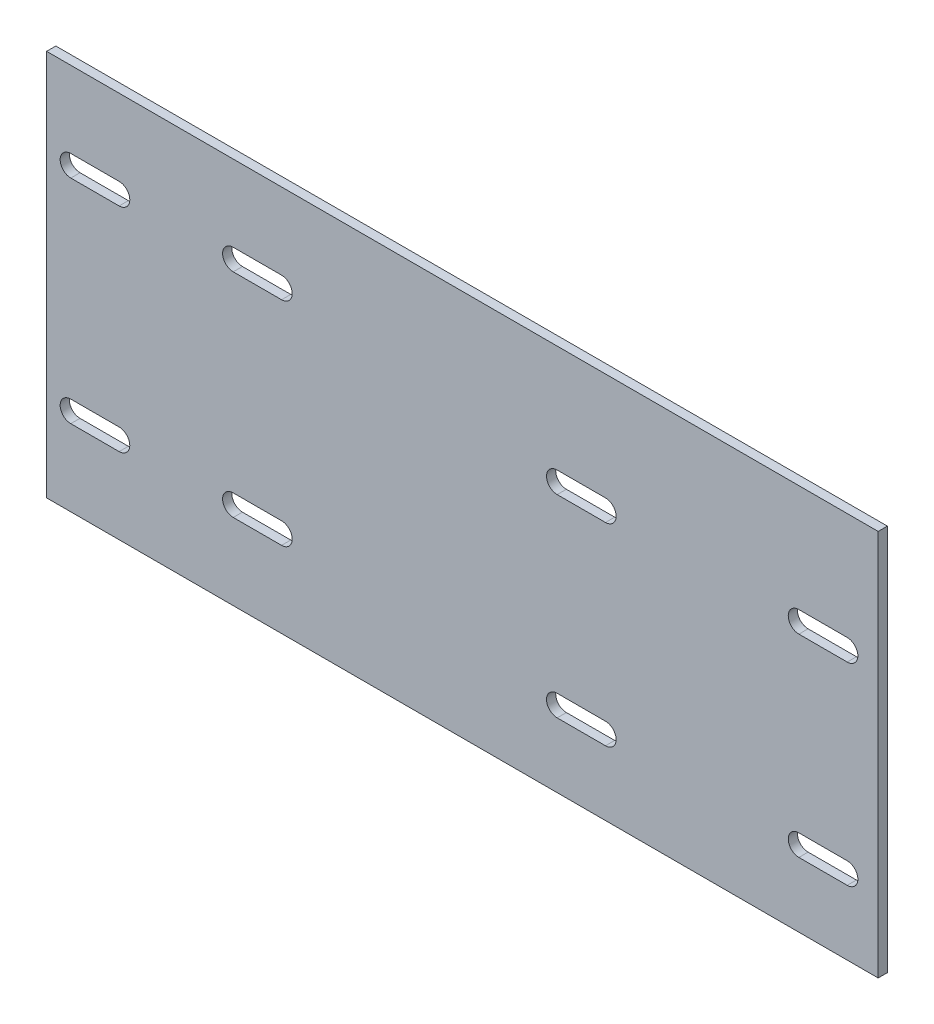
from build123d import *

# Parameters (mm, degrees)
ESBO_O1_W                = 430
ESBO_O1_H                = 200
RESSALTO_EXTRUS_O1_DEPTH = 4.7625
CORTE_EXTRUS_O1_DEPTH    = 5.7625


with BuildPart() as part:
    # Esboço1 → Ressalto-extrusão1 (new body)
    with BuildSketch(Plane.XY):
        Rectangle(ESBO_O1_W, ESBO_O1_H)
    extrude(amount=RESSALTO_EXTRUS_O1_DEPTH)

    # Esboço2 → Corte-extrusão1 (cut, through all)
    with BuildSketch(Plane.XY.offset(4.7625)):
        with BuildLine():
            Line((-202.5, 60.5), (-177.5, 60.5))
            ThreePointArc((-177.5, 60.5), (-172, 55), (-177.5, 49.5))
            Line((-177.5, 49.5), (-202.5, 49.5))
            ThreePointArc((-202.5, 49.5), (-208, 55), (-202.5, 60.5))
        make_face()
        with BuildLine():
            Line((-93.5, 49.5), (-118.5, 49.5))
            ThreePointArc((-118.5, 49.5), (-124, 55), (-118.5, 60.5))
            Line((-118.5, 60.5), (-93.5, 60.5))
            ThreePointArc((-93.5, 60.5), (-88, 55), (-93.5, 49.5))
        make_face()
        with BuildLine():
            Line((-202.5, -49.5), (-177.5, -49.5))
            ThreePointArc((-177.5, -49.5), (-172, -55), (-177.5, -60.5))
            Line((-177.5, -60.5), (-202.5, -60.5))
            ThreePointArc((-202.5, -60.5), (-208, -55), (-202.5, -49.5))
        make_face()
        with BuildLine():
            Line((-93.5, -60.5), (-118.5, -60.5))
            ThreePointArc((-118.5, -60.5), (-124, -55), (-118.5, -49.5))
            Line((-118.5, -49.5), (-93.5, -49.5))
            ThreePointArc((-93.5, -49.5), (-88, -55), (-93.5, -60.5))
        make_face()
        with BuildLine():
            Line((49, 44.5), (74, 44.5))
            ThreePointArc((74, 44.5), (79.5, 39), (74, 33.5))
            Line((74, 33.5), (49, 33.5))
            ThreePointArc((49, 33.5), (43.5, 39), (49, 44.5))
        make_face()
        with BuildLine():
            Line((199, 33.5), (174, 33.5))
            ThreePointArc((174, 33.5), (168.5, 39), (174, 44.5))
            Line((174, 44.5), (199, 44.5))
            ThreePointArc((199, 44.5), (204.5, 39), (199, 33.5))
        make_face()
        with BuildLine():
            Line((49, -55.5), (74, -55.5))
            ThreePointArc((74, -55.5), (79.5, -61), (74, -66.5))
            Line((74, -66.5), (49, -66.5))
            ThreePointArc((49, -66.5), (43.5, -61), (49, -55.5))
        make_face()
        with BuildLine():
            Line((199, -66.5), (174, -66.5))
            ThreePointArc((174, -66.5), (168.5, -61), (174, -55.5))
            Line((174, -55.5), (199, -55.5))
            ThreePointArc((199, -55.5), (204.5, -61), (199, -66.5))
        make_face()
    extrude(amount=-CORTE_EXTRUS_O1_DEPTH, mode=Mode.SUBTRACT)


solid = part.part
